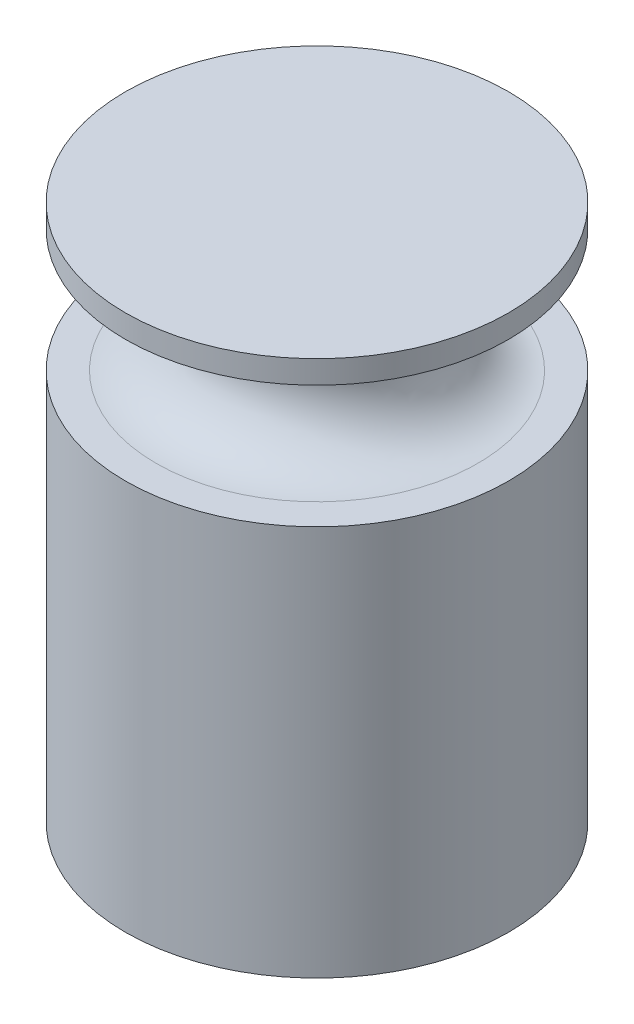
from build123d import *


with BuildPart() as part:
    # Sketch1 → Revolve1 (revolve)
    with BuildSketch(Plane.XY):
        with BuildLine():
            Line((0, 0), (0, 70))
            Line((0, 70), (25, 70))
            Line((25, 70), (25, 67))
            Line((25, 67), (21, 67))
            ThreePointArc((21, 67), (13, 59), (21, 51))
            Line((21, 51), (25, 51))
            Line((25, 51), (25, 0))
            Line((25, 0), (0, 0))
        make_face()
    revolve(axis=Axis((0, 0, 0), (0, 1, 0)))


solid = part.part
